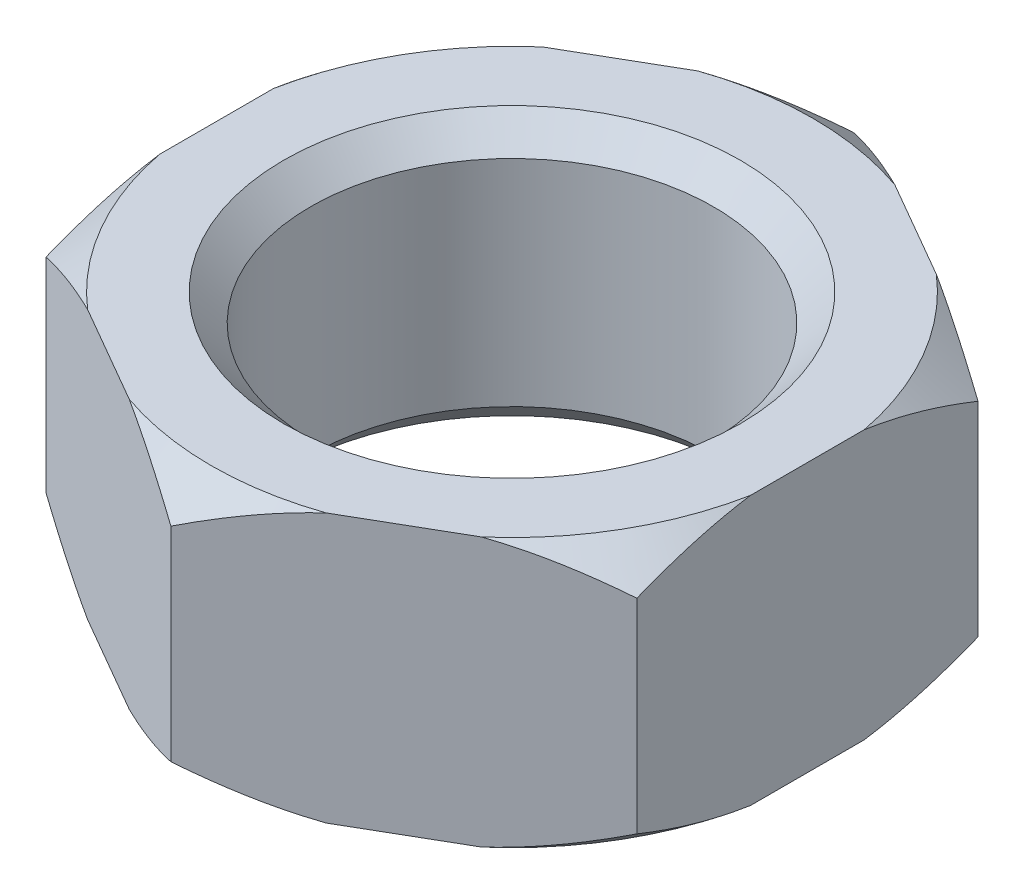
from build123d import *

# Parameters (mm, degrees)
BOSS_EXTRUDE1_DEPTH = 10
SKETCH2_R           = 7.5
CUT_EXTRUDE1_DEPTH  = 11
CHAMFER1_SIZE       = 1
SCALE2_SCALE        = 0.18
SCALE3_SCALE        = 1.04


with BuildPart() as part:
    # Sketch1 → Boss-Extrude1 (new body)
    with BuildSketch(Plane(origin=(0, 0, 0), x_dir=(1, 0, 0), z_dir=(0, 1, 0))):
        Polygon((0, 12.701705922), (-11, 6.350852961), (-11, -6.350852961), (0, -12.701705922), (11, -6.350852961), (11, 6.350852961), align=None)
    extrude(amount=BOSS_EXTRUDE1_DEPTH)

    # Sketch2 → Cut-Extrude1 (cut, through all)
    with BuildSketch(Plane(origin=(0, 10, 0), x_dir=(1, 0, 0), z_dir=(0, 1, 0))):
        Circle(SKETCH2_R)
    extrude(amount=-CUT_EXTRUDE1_DEPTH, mode=Mode.SUBTRACT)

    # Chamfer1
    chamfer1_edges = [part.edges().sort_by_distance(p)[0] for p in [
        (-7.5, 0, 0),
        (-7.5, 10, 0),
    ]]
    chamfer(chamfer1_edges, length=CHAMFER1_SIZE)

    # Sketch3 → Cut-Revolve1 (revolve, cut)
    with BuildSketch(Plane(origin=(0, 0, 0), x_dir=(0, 0, -1), z_dir=(1, 0, 0))):
        Polygon((-12.701705922, 10), (-12.701705922, 8.8), (-11.201705922, 10), align=None)
        Polygon((-12.701705922, 0), (-12.701705922, 1.2), (-11.201705922, 0), align=None)
    revolve(axis=Axis((0, 10, 0), (0, -1, 0)), mode=Mode.SUBTRACT)


with BuildPart() as part_1:
    # Scale2: scaled about (0, 5, 0)
    add(part.part.scale(SCALE2_SCALE).moved(Location((0, 4.1, 0))))


with BuildPart() as part_2:
    # Scale3: scaled about (0, 5, 0)
    add(part_1.part.scale(SCALE3_SCALE).moved(Location((0, -0.2, 0))))


solid = part_2.part
